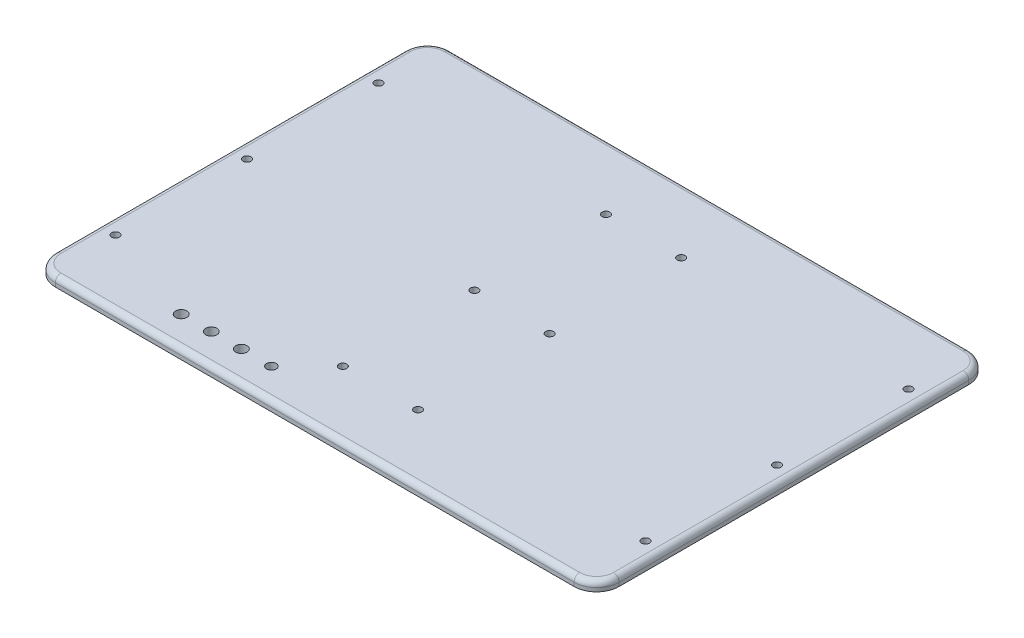
from build123d import *

# Parameters (mm, degrees)
SKETCH1_W           = 300
SKETCH1_H           = 210
BOSS_EXTRUDE1_DEPTH = 5
FILLET1_R           = 12
SKETCH2_R           = 2.075
CUT_EXTRUDE1_DEPTH  = 6
FILLET2_R           = 3
SKETCH3_R           = 3
SKETCH3_R_2         = 2.56
CUT_EXTRUDE2_DEPTH  = 6


with BuildPart() as part:
    # Sketch1 → Boss-Extrude1 (new body)
    with BuildSketch(Plane(origin=(0, 0, 0), x_dir=(1, 0, 0), z_dir=(0, 1, 0))):
        Rectangle(SKETCH1_W, SKETCH1_H)
    extrude(amount=BOSS_EXTRUDE1_DEPTH)

    # Fillet1
    fillet1_edges = [part.edges().sort_by_distance(p)[0] for p in [
        (150, 2.5, 105),
        (-150, 2.5, 105),
        (-150, 2.5, -105),
        (150, 2.5, -105),
    ]]
    fillet(fillet1_edges, radius=FILLET1_R)

    # Sketch2 → Cut-Extrude1 (cut, through all)
    with BuildSketch(Plane(origin=(0, 5, 0), x_dir=(1, 0, 0), z_dir=(0, 1, 0))):
        with Locations((-141, 70)):
            Circle(SKETCH2_R)
        with Locations((-141, 0)):
            Circle(SKETCH2_R)
        with Locations((-141, -70)):
            Circle(SKETCH2_R)
        with Locations((-20, 70)):
            Circle(SKETCH2_R)
        with Locations((-20, 0)):
            Circle(SKETCH2_R)
        with Locations((-20, -70)):
            Circle(SKETCH2_R)
    cut_extrude1 = extrude(amount=-CUT_EXTRUDE1_DEPTH, mode=Mode.SUBTRACT)

    # Mirror1: Cut-Extrude1 across plane
    add(cut_extrude1.mirror(Plane(origin=(0, 0, 0), x_dir=(0, 0, 1), z_dir=(1, 0, 0))), mode=Mode.SUBTRACT)

    # Fillet2
    fillet2_edges = [part.edges().sort_by_distance(p)[0] for p in [
        (0, 5, -105),
        (150, 5, 0),
        (-150, 5, 0),
        (0, 5, 105),
        (-146.485281374, 5, -101.485281374),
        (-146.485281374, 5, 101.485281374),
        (146.485281374, 5, 101.485281374),
        (146.485281374, 5, -101.485281374),
    ]]
    fillet(fillet2_edges, radius=FILLET2_R)

    # Sketch3 → Cut-Extrude2 (cut, through all)
    with BuildSketch(Plane(origin=(0, 5, 0), x_dir=(1, 0, 0), z_dir=(0, 1, 0))):
        with Locations((-87, -89)):
            Circle(SKETCH3_R)
        with Locations((-71, -89)):
            Circle(SKETCH3_R)
        with Locations((-55, -89)):
            Circle(SKETCH3_R)
        with Locations((-39, -89)):
            Circle(SKETCH3_R_2)
    extrude(amount=-CUT_EXTRUDE2_DEPTH, mode=Mode.SUBTRACT)


solid = part.part
